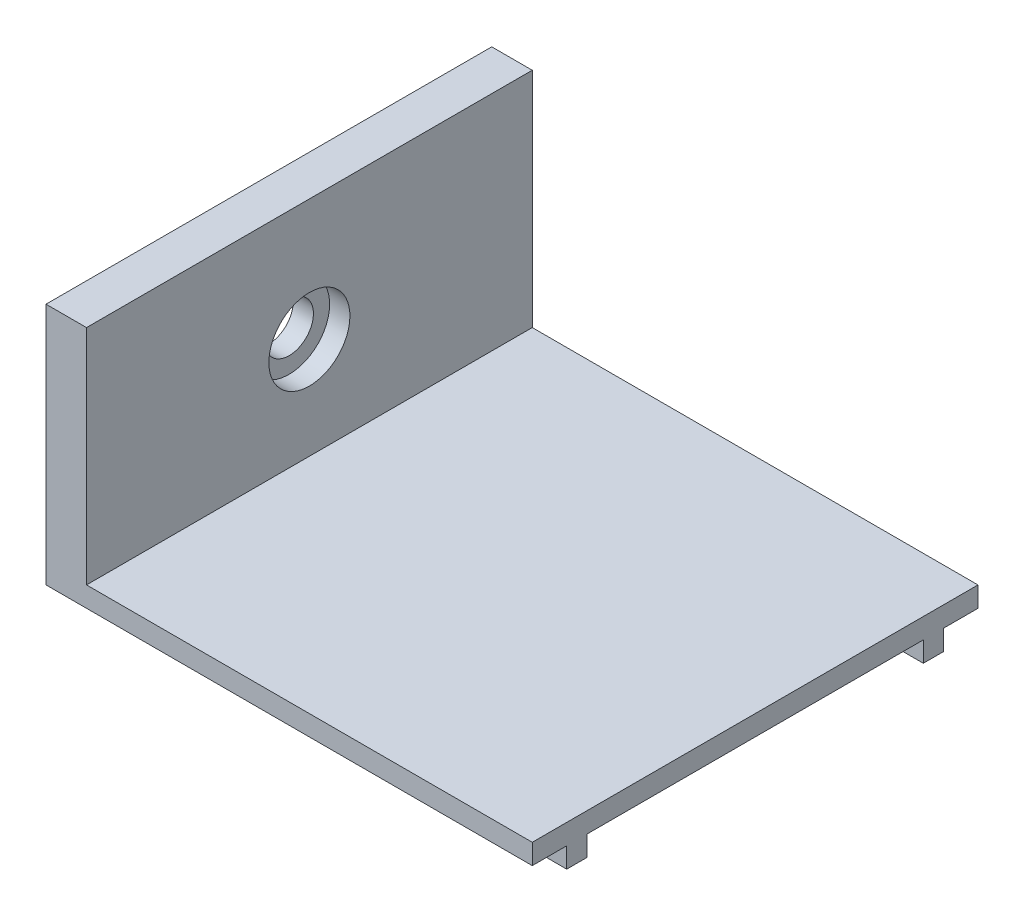
from build123d import *

# Parameters (mm, degrees)
BOSS_EXTRUDE2_DEPTH = 110
BOSS_EXTRUDE3_DEPTH = 5
SKETCH4_R           = 6
CUT_EXTRUDE1_DEPTH  = 5
SKETCH5_R           = 10
CUT_EXTRUDE2_DEPTH  = 5


with BuildPart() as part:
    # Sketch2 → Boss-Extrude2 (new body)
    with BuildSketch(Plane.XY):
        Polygon((0, 0), (0, 60), (10, 60), (10, 5), (120, 5), (120, 0), align=None)
    extrude(amount=BOSS_EXTRUDE2_DEPTH)

    # Sketch3 → Boss-Extrude3 (add)
    with BuildSketch(Plane.XZ):
        Polygon((60, 101.5), (0, 101.5), (0, 96.5), (120, 96.5), (120, 101.5), align=None)
        Polygon((120, 13.5), (0, 13.5), (0, 8.5), (60, 8.5), (120, 8.5), align=None)
    extrude(amount=BOSS_EXTRUDE3_DEPTH)

    # Sketch4 → Cut-Extrude1 (cut)
    with BuildSketch(Plane.ZY):
        with Locations((55, 30)):
            Circle(SKETCH4_R)
    extrude(amount=-CUT_EXTRUDE1_DEPTH, mode=Mode.SUBTRACT)

    # Sketch5 → Cut-Extrude2 (cut)
    with BuildSketch(Plane(origin=(10, 0, 0), x_dir=(0, 0, -1), z_dir=(1, 0, 0))):
        with Locations((-55, 30)):
            Circle(SKETCH5_R)
    extrude(amount=-CUT_EXTRUDE2_DEPTH, mode=Mode.SUBTRACT)


solid = part.part
